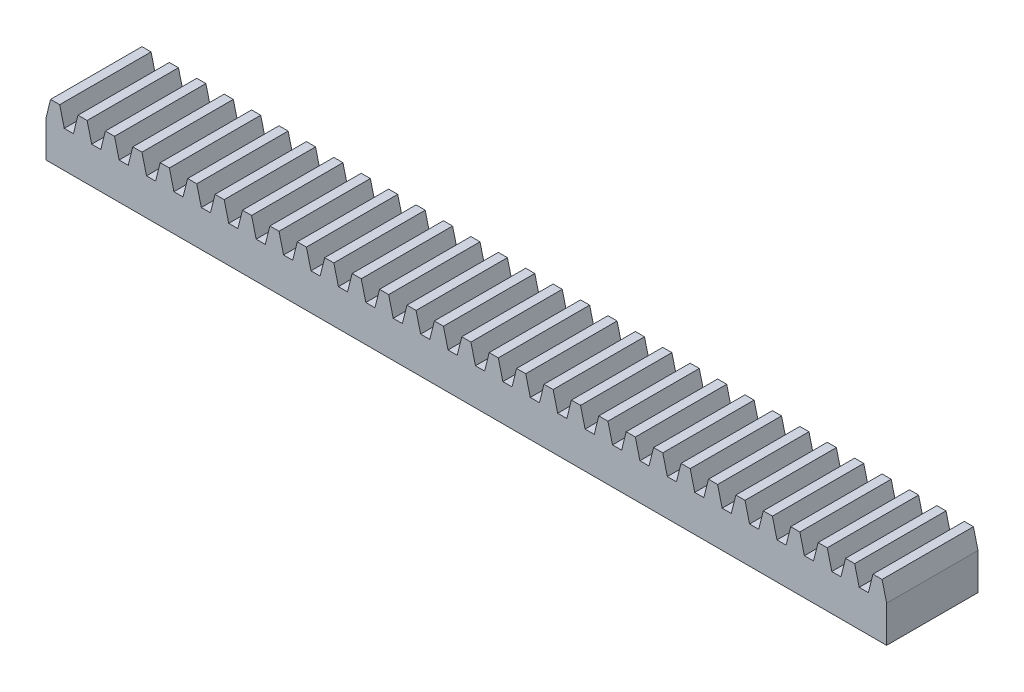
from build123d import *

# Parameters (mm, degrees)
BOSS_EXTRUDE1_DEPTH = 25.4


with BuildPart() as part:
    # Sketch1 → Boss-Extrude1 (new body)
    with BuildSketch(Plane.XY):
        Polygon((0, 0), (233.68, 0), (233.68, 10.16), (232.41, 15.24), (229.87, 15.24), (228.6, 10.16), (226.06, 10.16), (224.79, 15.24), (222.25, 15.24), (220.98, 10.16), (218.44, 10.16), (217.17, 15.24), (214.63, 15.24), (213.36, 10.16), (210.82, 10.16), (209.55, 15.24), (207.01, 15.24), (205.74, 10.16), (203.2, 10.16), (201.93, 15.24), (199.39, 15.24), (198.12, 10.16), (195.58, 10.16), (194.31, 15.24), (191.77, 15.24), (190.5, 10.16), (187.96, 10.16), (186.69, 15.24), (184.15, 15.24), (182.88, 10.16), (180.34, 10.16), (179.07, 15.24), (176.53, 15.24), (175.26, 10.16), (172.72, 10.16), (171.45, 15.24), (168.91, 15.24), (167.64, 10.16), (165.1, 10.16), (163.83, 15.24), (161.29, 15.24), (160.02, 10.16), (157.48, 10.16), (156.21, 15.24), (153.67, 15.24), (152.4, 10.16), (149.86, 10.16), (148.59, 15.24), (146.05, 15.24), (144.78, 10.16), (142.24, 10.16), (140.97, 15.24), (138.43, 15.24), (137.16, 10.16), (134.62, 10.16), (133.35, 15.24), (130.81, 15.24), (129.54, 10.16), (127, 10.16), (125.73, 15.24), (123.19, 15.24), (121.92, 10.16), (119.38, 10.16), (118.11, 15.24), (115.57, 15.24), (114.3, 10.16), (111.76, 10.16), (110.49, 15.24), (107.95, 15.24), (106.68, 10.16), (104.14, 10.16), (102.87, 15.24), (100.33, 15.24), (99.06, 10.16), (96.52, 10.16), (95.25, 15.24), (92.71, 15.24), (91.44, 10.16), (88.9, 10.16), (87.63, 15.24), (85.09, 15.24), (83.82, 10.16), (81.28, 10.16), (80.01, 15.24), (77.47, 15.24), (76.2, 10.16), (73.66, 10.16), (72.39, 15.24), (69.85, 15.24), (68.58, 10.16), (66.04, 10.16), (64.77, 15.24), (62.23, 15.24), (60.96, 10.16), (58.42, 10.16), (57.15, 15.24), (54.61, 15.24), (53.34, 10.16), (50.8, 10.16), (49.53, 15.24), (46.99, 15.24), (45.72, 10.16), (43.18, 10.16), (41.91, 15.24), (39.37, 15.24), (38.1, 10.16), (35.56, 10.16), (34.29, 15.24), (31.75, 15.24), (30.48, 10.16), (27.94, 10.16), (26.67, 15.24), (24.13, 15.24), (22.86, 10.16), (20.32, 10.16), (19.05, 15.24), (16.51, 15.24), (15.24, 10.16), (12.7, 10.16), (11.43, 15.24), (8.89, 15.24), (7.62, 10.16), (5.08, 10.16), (3.81, 15.24), (1.27, 15.24), (0, 10.16), align=None)
    extrude(amount=BOSS_EXTRUDE1_DEPTH)


solid = part.part
